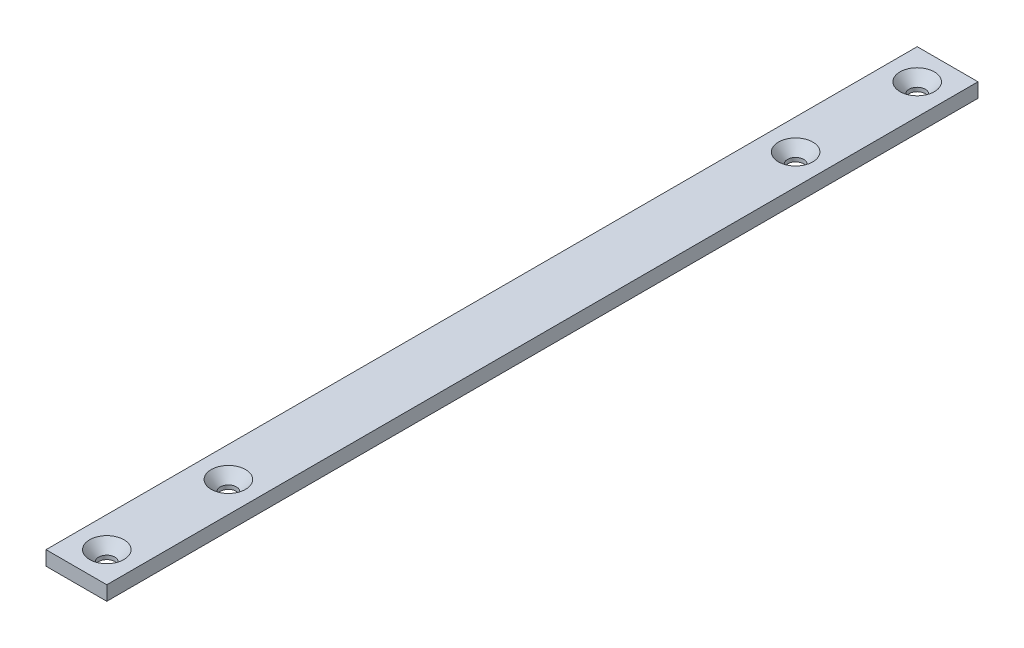
from build123d import *

# Parameters (mm, degrees)
SKETCH3_W                                    = 25.4
SKETCH3_H                                    = 6
BOSS_EXTRUDE1_DEPTH                          = 182
CSK_FOR_1_4_FLAT_HEAD_SOCKET_CAP_SCR_2_COUNT = 2
CSK_FOR_1_4_FLAT_HEAD_SOCKET_CAP_SCR_2_PITCH = 338.6
CSK_FOR_1_4_FLAT_HEAD_SOCKET_CAP_SCR_3_COUNT = 2
CSK_FOR_1_4_FLAT_HEAD_SOCKET_CAP_SCR_3_PITCH = 50.8
CSK_FOR_1_4_FLAT_HEAD_SOCKET_CAP_SCR_4_COUNT = 2
CSK_FOR_1_4_FLAT_HEAD_SOCKET_CAP_SCR_4_PITCH = 287.8


with BuildPart() as part:
    # Sketch3 → Boss-Extrude1 (new body, symmetric)
    with BuildSketch(Plane.XY):
        Rectangle(SKETCH3_W, SKETCH3_H)
    extrude(amount=BOSS_EXTRUDE1_DEPTH, both=True)

    # Sketch8 → CSK for 1/4 Flat Head Socket Cap Screw1 (revolve, cut)
    with BuildSketch(Plane(origin=(0, 3, -169.3), x_dir=(0, 0, 1), z_dir=(1, 0, 0))):
        Polygon((0, 0), (0, 6), (3.3782, 6), (3.3782, 4.371566521), (7.1783448, 0), align=None)
    csk_for_1_4_flat_head_socket_cap_screw1 = revolve(axis=Axis((0, 9.35, -169.3), (0, -1, 0)), mode=Mode.SUBTRACT)

    # CSK for 1_4 Flat Head Socket Cap Scr 2: CSK for 1/4 Flat Head Socket Cap Screw1 ×2
    with Locations(*[(0, 0, i * CSK_FOR_1_4_FLAT_HEAD_SOCKET_CAP_SCR_2_PITCH) for i in range(1, CSK_FOR_1_4_FLAT_HEAD_SOCKET_CAP_SCR_2_COUNT)]):
        add(csk_for_1_4_flat_head_socket_cap_screw1, mode=Mode.SUBTRACT)

    # CSK for 1_4 Flat Head Socket Cap Scr 3: CSK for 1/4 Flat Head Socket Cap Screw1 ×2
    with Locations(*[(0, 0, i * CSK_FOR_1_4_FLAT_HEAD_SOCKET_CAP_SCR_3_PITCH) for i in range(1, CSK_FOR_1_4_FLAT_HEAD_SOCKET_CAP_SCR_3_COUNT)]):
        add(csk_for_1_4_flat_head_socket_cap_screw1, mode=Mode.SUBTRACT)

    # CSK for 1_4 Flat Head Socket Cap Scr 4: CSK for 1/4 Flat Head Socket Cap Screw1 ×2
    with Locations(*[(0, 0, i * CSK_FOR_1_4_FLAT_HEAD_SOCKET_CAP_SCR_4_PITCH) for i in range(1, CSK_FOR_1_4_FLAT_HEAD_SOCKET_CAP_SCR_4_COUNT)]):
        add(csk_for_1_4_flat_head_socket_cap_screw1, mode=Mode.SUBTRACT)


solid = part.part
